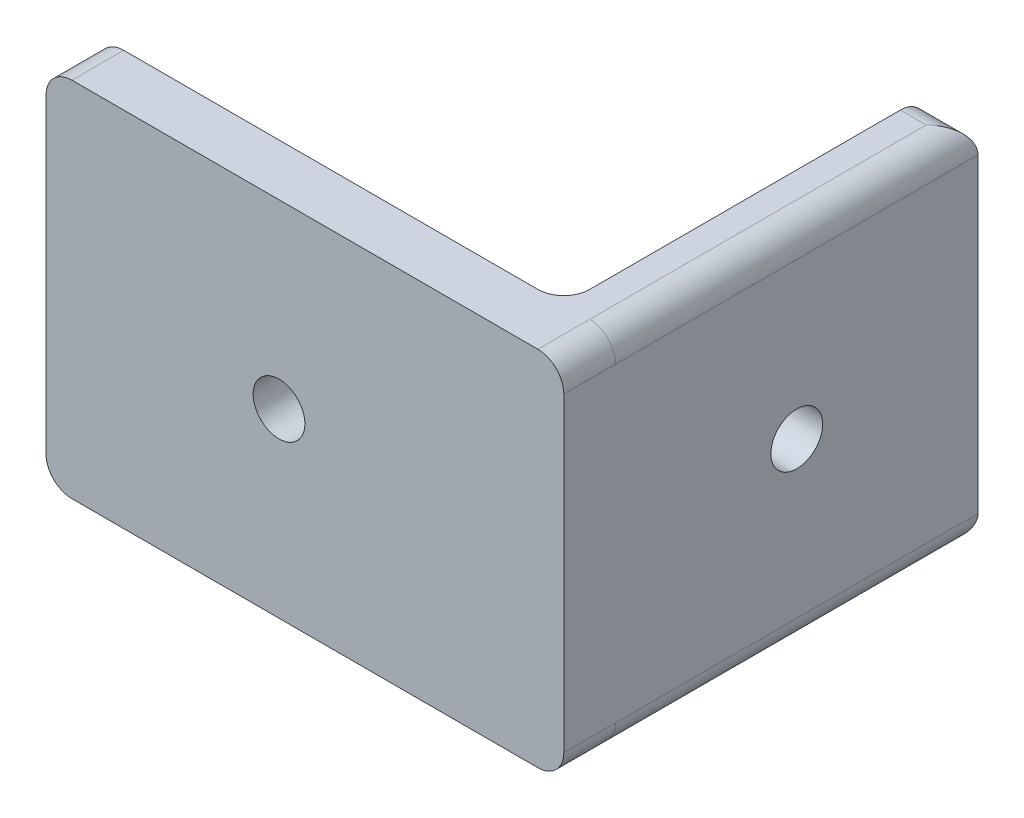
from build123d import *

# Parameters (mm, degrees)
BOSS_EXTRUDE1_DEPTH = 20
BOSS_EXTRUDE2_DEPTH = 140
FILLET1_R           = 10
SKETCH3_R           = 9.999999999999993
CUT_EXTRUDE1_DEPTH  = 282.42494558940575
SKETCH4_R           = 9.999999999999993
CUT_EXTRUDE2_DEPTH  = 279.5677655436824


with BuildPart() as part:
    # Sketch1 → Boss-Extrude1 (new body)
    with BuildSketch(Plane.XY):
        with BuildLine():
            Line((10.000000000000071, 0), (189.99999999999994, 0))
            ThreePointArc((189.99999999999994, 0), (197.07106781186548, 2.92893218813453), (200, 10.000000000000071))
            Line((200, 10.000000000000071), (200, 129.99999999999994))
            ThreePointArc((200, 129.99999999999994), (197.07106781186548, 137.07106781186548), (189.99999999999994, 140))
            Line((189.99999999999994, 140), (10.000000000000071, 140))
            ThreePointArc((10.000000000000071, 140), (2.9289321881345263, 137.07106781186548), (0, 129.99999999999994))
            Line((0, 129.99999999999994), (0, 10.000000000000071))
            ThreePointArc((0, 10.000000000000071), (2.9289321881345254, 2.9289321881345245), (10.000000000000071, 0))
        make_face()
    extrude(amount=-BOSS_EXTRUDE1_DEPTH)

    # Sketch2 → Boss-Extrude2 (add)
    with BuildSketch(Plane(origin=(0, 0, -20), x_dir=(-1, 0, 0), z_dir=(0, 0, -1))):
        Polygon((-180, 140), (-200, 140), (-200, 0), (-179.99999999999997, 2.45e-15), align=None)
    extrude(amount=BOSS_EXTRUDE2_DEPTH)

    # Fillet1
    fillet1_edges = [part.edges().sort_by_distance(p)[0] for p in [
        (190, 1.22e-15, -160),
        (190, 140, -160),
        (180, 70, -20),
        (200, 0, -90),
        (200, 140, -90),
    ]]
    fillet(fillet1_edges, radius=FILLET1_R)

    # Sketch3 → Cut-Extrude1 (cut, through all)
    with BuildSketch(Plane(origin=(0, 0, -20), x_dir=(-1, 0, 0), z_dir=(0, 0, -1))):
        with Locations((-89.99999999999997, 70)):
            Circle(SKETCH3_R)
    extrude(amount=-CUT_EXTRUDE1_DEPTH, mode=Mode.SUBTRACT)

    # Sketch4 → Cut-Extrude2 (cut, through all)
    with BuildSketch(Plane.ZY.offset(-179.99999999999997)):
        with Locations(Location((-90.00000000000001, 70.00000000000003, 0), (0, 0, 270))):
            Circle(SKETCH4_R)
    extrude(amount=-CUT_EXTRUDE2_DEPTH, mode=Mode.SUBTRACT)


solid = part.part
